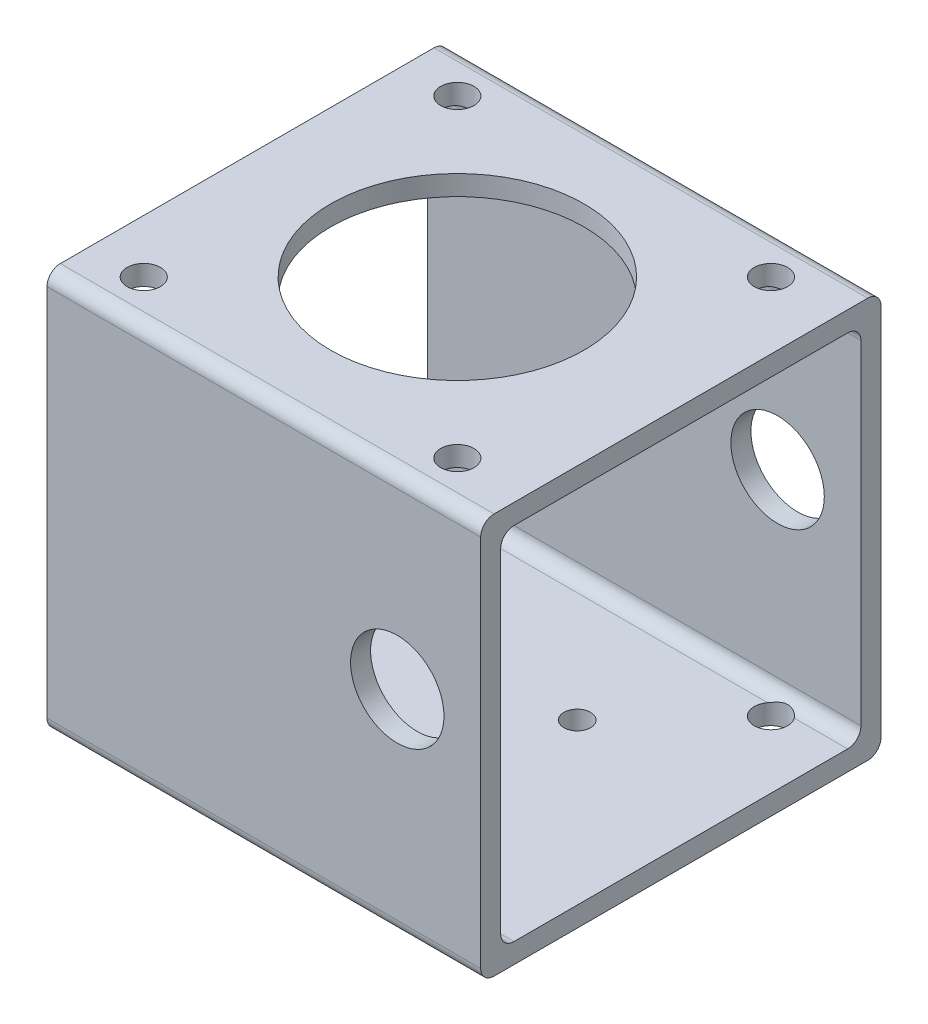
from build123d import *

# Parameters (mm, degrees)
EXTRUDE_1_DEPTH     = 65
SKETCH_2_R          = 2.5
CUT_EXTRUDE_1_DEPTH = 61
SKETCH_3_R          = 7
CUT_EXTRUDE_2_DEPTH = 61
CUT_EXTRUDE_4_REACH = 62
SKETCH_7_R          = 2
CUT_EXTRUDE_5_REACH = 62
SKETCH_8_R          = 19


with BuildPart() as part:
    # 草图1 → 凸台-拉伸1 (new body)
    with BuildSketch(Plane(origin=(0, 0, 0), x_dir=(0, 0, -1), z_dir=(1, 0, 0))):
        with BuildLine():
            Line((60, 2), (60, 58))
            ThreePointArc((60, 58), (59.414213562, 59.414213562), (58, 60))
            Line((58, 60), (2, 60))
            ThreePointArc((2, 60), (0.585786438, 59.414213562), (0, 58))
            Line((0, 58), (0, 2))
            ThreePointArc((0, 2), (0.585786438, 0.585786438), (2, 0))
            Line((2, 0), (58, 0))
            ThreePointArc((58, 0), (59.414213562, 0.585786438), (60, 2))
        make_face()
        with BuildLine():
            Line((3, 5), (3, 55))
            ThreePointArc((3, 55), (3.585786438, 56.414213562), (5, 57))
            Line((5, 57), (55, 57))
            ThreePointArc((55, 57), (56.414213562, 56.414213562), (57, 55))
            Line((57, 55), (57, 5))
            ThreePointArc((57, 5), (56.414213562, 3.585786438), (55, 3))
            Line((55, 3), (5, 3))
            ThreePointArc((5, 3), (3.585786438, 3.585786438), (3, 5))
        make_face(mode=Mode.SUBTRACT)
    extrude(amount=EXTRUDE_1_DEPTH)

    # 草图2 → 切除-拉伸1 (cut, through all)
    with BuildSketch(Plane(origin=(0, 60, 0), x_dir=(1, 0, 0), z_dir=(0, 1, 0))):
        with Locations((8, 6.5)):
            Circle(SKETCH_2_R)
        with Locations((55, 6.5)):
            Circle(SKETCH_2_R)
        with Locations((55, 53.5)):
            Circle(SKETCH_2_R)
        with Locations((8, 53.5)):
            Circle(SKETCH_2_R)
    extrude(amount=-CUT_EXTRUDE_1_DEPTH, mode=Mode.SUBTRACT)

    # 草图3 → 切除-拉伸2 (cut, through all)
    with BuildSketch(Plane.XY):
        with Locations((52.5, 32)):
            Circle(SKETCH_3_R)
    extrude(amount=-CUT_EXTRUDE_2_DEPTH, mode=Mode.SUBTRACT)

    # 草图7 → 切除-拉伸4 (cut, up to next)
    with BuildSketch(Plane.XZ, mode=Mode.PRIVATE) as cut_extrude_4_sk1:
        with Locations((40.985281374, -38.485281374)):
            Circle(SKETCH_7_R)
    cut_extrude_4_tool1 = extrude(cut_extrude_4_sk1.sketch, amount=-CUT_EXTRUDE_4_REACH, mode=Mode.PRIVATE) & part.part
    add(cut_extrude_4_tool1.solids().sort_by_distance((40.985281, 0, -38.485281))[0], mode=Mode.SUBTRACT)
    # 草图7 → 切除-拉伸4 (cut, up to next)
    with BuildSketch(Plane.XZ, mode=Mode.PRIVATE) as cut_extrude_4_sk2:
        with Locations((24.014718626, -38.485281374)):
            Circle(SKETCH_7_R)
    cut_extrude_4_tool2 = extrude(cut_extrude_4_sk2.sketch, amount=-CUT_EXTRUDE_4_REACH, mode=Mode.PRIVATE) & part.part
    add(cut_extrude_4_tool2.solids().sort_by_distance((24.014719, 0, -38.485281))[0], mode=Mode.SUBTRACT)
    # 草图7 → 切除-拉伸4 (cut, up to next)
    with BuildSketch(Plane.XZ, mode=Mode.PRIVATE) as cut_extrude_4_sk3:
        with Locations((24.014718626, -21.514718626)):
            Circle(SKETCH_7_R)
    cut_extrude_4_tool3 = extrude(cut_extrude_4_sk3.sketch, amount=-CUT_EXTRUDE_4_REACH, mode=Mode.PRIVATE) & part.part
    add(cut_extrude_4_tool3.solids().sort_by_distance((24.014719, 0, -21.514719))[0], mode=Mode.SUBTRACT)
    # 草图7 → 切除-拉伸4 (cut, up to next)
    with BuildSketch(Plane.XZ, mode=Mode.PRIVATE) as cut_extrude_4_sk4:
        with Locations((40.985281374, -21.514718626)):
            Circle(SKETCH_7_R)
    cut_extrude_4_tool4 = extrude(cut_extrude_4_sk4.sketch, amount=-CUT_EXTRUDE_4_REACH, mode=Mode.PRIVATE) & part.part
    add(cut_extrude_4_tool4.solids().sort_by_distance((40.985281, 0, -21.514719))[0], mode=Mode.SUBTRACT)

    # 草图8 → 切除-拉伸5 (cut, up to next)
    with BuildSketch(Plane(origin=(0, 60, 0), x_dir=(1, 0, 0), z_dir=(0, 1, 0)), mode=Mode.PRIVATE) as cut_extrude_5_sk1:
        with Locations((31.5, 30)):
            Circle(SKETCH_8_R)
    cut_extrude_5_tool1 = extrude(cut_extrude_5_sk1.sketch, amount=-CUT_EXTRUDE_5_REACH, mode=Mode.PRIVATE) & part.part
    add(cut_extrude_5_tool1.solids().sort_by_distance((31.5, 60, -30))[0], mode=Mode.SUBTRACT)


solid = part.part
